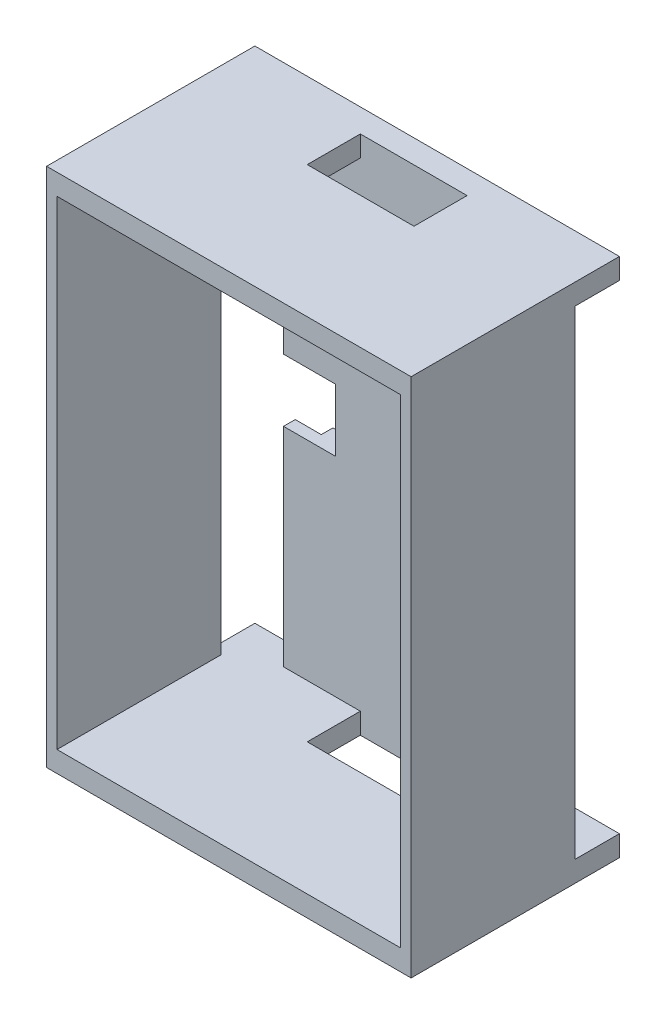
from build123d import *

# Parameters (mm, degrees)
SKETCH1_W           = 70
SKETCH1_H           = 100
BOSS_EXTRUDE1_DEPTH = 40
SKETCH2_W           = 66
SKETCH2_H           = 92
CUT_EXTRUDE1_DEPTH  = 33
SKETCH3_W           = 4
SKETCH3_H           = 92
CUT_EXTRUDE2_DEPTH  = 71
SKETCH4_R           = 10.75
CUT_EXTRUDE3_DEPTH  = 3.5
CUT_EXTRUDE4_DEPTH  = 5.5
SKETCH6_R           = 1.1
CUT_EXTRUDE5_DEPTH  = 3
SKETCH11_W          = 10
SKETCH11_H          = 92
CUT_EXTRUDE9_DEPTH  = 10
SKETCH12_W          = 2.25
SKETCH12_H          = 40
CUT_EXTRUDE10_DEPTH = 5
SKETCH13_W          = 2.25
SKETCH13_H          = 40
CUT_EXTRUDE11_DEPTH = 5
SKETCH16_R          = 11.75
BOSS_EXTRUDE3_DEPTH = 8.5
SKETCH17_R          = 10.7
CUT_EXTRUDE13_DEPTH = 10
SKETCH19_W          = 20.5
SKETCH19_H          = 10.2
CUT_EXTRUDE14_DEPTH = 101


with BuildPart() as part:
    # Sketch1 → Boss-Extrude1 (new body)
    with BuildSketch(Plane.XY):
        Rectangle(SKETCH1_W, SKETCH1_H)
    extrude(amount=BOSS_EXTRUDE1_DEPTH)

    # Sketch2 → Cut-Extrude1 (cut)
    with BuildSketch(Plane.XY.offset(40)):
        Rectangle(SKETCH2_W, SKETCH2_H)
    extrude(amount=-CUT_EXTRUDE1_DEPTH, mode=Mode.SUBTRACT)

    # Sketch3 → Cut-Extrude2 (cut, through all)
    with BuildSketch(Plane.ZY.offset(35)):
        with Locations((6.5, 0)):
            Rectangle(SKETCH3_W, SKETCH3_H)
    extrude(amount=-CUT_EXTRUDE2_DEPTH, mode=Mode.SUBTRACT)

    # Sketch4 → Cut-Extrude3 (cut)
    with BuildSketch(Plane(origin=(0, 0, 0), x_dir=(-1, 0, 0), z_dir=(0, 0, -1))):
        Circle(SKETCH4_R)
    extrude(amount=-CUT_EXTRUDE3_DEPTH, mode=Mode.SUBTRACT)

    # Sketch5 → Cut-Extrude4 (cut, through all)
    with BuildSketch(Plane.XY.offset(4.5)):
        Polygon((-15.010107583, -6), (-35.010107583, -6), (-35.010107583, 6), (-28.010107583, 6), (-22.010107583, 6), (-15.010107583, 6), align=None)
        Polygon((15.010107583, -6), (35.010107583, -6), (35.010107583, 6), (28.010107583, 6), (22.010107583, 6), (15.010107583, 6), align=None)
    extrude(amount=-CUT_EXTRUDE4_DEPTH, mode=Mode.SUBTRACT)

    # Sketch6 → Cut-Extrude5 (cut)
    with BuildSketch(Plane.XZ.offset(50)):
        with Locations((27, 8.9)):
            Circle(SKETCH6_R)
        with Locations((27, 17.4)):
            Circle(SKETCH6_R)
        with Locations((-27, 8.9)):
            Circle(SKETCH6_R)
        with Locations((-27, 17.4)):
            Circle(SKETCH6_R)
    extrude(amount=-CUT_EXTRUDE5_DEPTH, mode=Mode.SUBTRACT)

    # Sketch11 → Cut-Extrude9 (cut)
    with BuildSketch(Plane.XY.offset(4.5)):
        with Locations((-30, 0)):
            Rectangle(SKETCH11_W, SKETCH11_H)
        with Locations((30, 0)):
            Rectangle(SKETCH11_W, SKETCH11_H)
    extrude(amount=-CUT_EXTRUDE9_DEPTH, mode=Mode.SUBTRACT)

    # Sketch12 → Cut-Extrude10 (cut)
    with BuildSketch(Plane(origin=(25, 0, 0), x_dir=(0, 0, -1), z_dir=(1, 0, 0))):
        with Locations((-1.125, -26)):
            Rectangle(SKETCH12_W, SKETCH12_H)
    extrude(amount=-CUT_EXTRUDE10_DEPTH, mode=Mode.SUBTRACT)

    # Sketch13 → Cut-Extrude11 (cut)
    with BuildSketch(Plane.ZY.offset(25)):
        with Locations((1.125, -26)):
            Rectangle(SKETCH13_W, SKETCH13_H)
    extrude(amount=-CUT_EXTRUDE11_DEPTH, mode=Mode.SUBTRACT)

    # Sketch16 → Boss-Extrude3 (add)
    with BuildSketch(Plane(origin=(0, 0, 0), x_dir=(-1, 0, 0), z_dir=(0, 0, -1))):
        Circle(SKETCH16_R)
    extrude(amount=BOSS_EXTRUDE3_DEPTH)

    # Sketch17 → Cut-Extrude13 (cut)
    with BuildSketch(Plane(origin=(0, 0, -8.5), x_dir=(-1, 0, 0), z_dir=(0, 0, -1))):
        Circle(SKETCH17_R)
    extrude(amount=-CUT_EXTRUDE13_DEPTH, mode=Mode.SUBTRACT)

    # Sketch19 → Cut-Extrude14 (cut, through all)
    with BuildSketch(Plane(origin=(0, 50, 0), x_dir=(1, 0, 0), z_dir=(0, 1, 0))):
        with Locations((0, -9.6)):
            Rectangle(SKETCH19_W, SKETCH19_H)
    extrude(amount=-CUT_EXTRUDE14_DEPTH, mode=Mode.SUBTRACT)


solid = part.part
